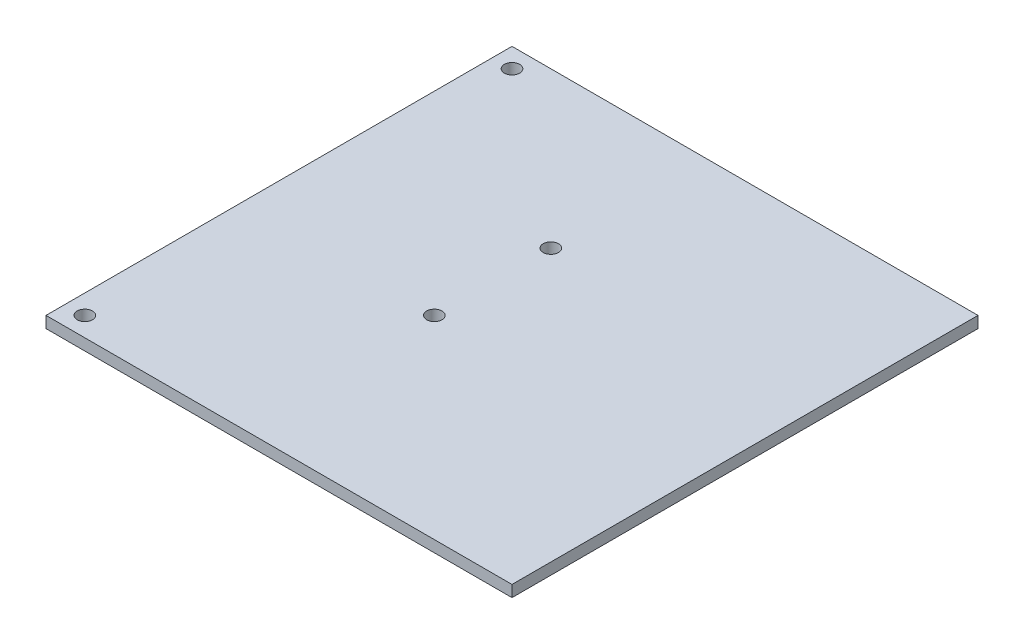
from build123d import *

# Parameters (mm, degrees)
SKETCH1_W           = 60.96
SKETCH1_H           = 60.96
SKETCH1_R           = 1
SKETCH1_R_2         = 0.5
BOSS_EXTRUDE1_DEPTH = 1.5
SKETCH1_3_R         = 0.5
CUT_EXTRUDE1_DEPTH  = 0.75


with BuildPart() as part:
    # Sketch1 → Boss-Extrude1 (new body)
    with BuildSketch(Plane(origin=(0, 0, 0), x_dir=(1, 0, 0), z_dir=(0, 1, 0))):
        with Locations((30.48, 30.48)):
            Rectangle(SKETCH1_W, SKETCH1_H)
        with Locations(Location((25.4, 40.64, 0), (0, 0, 270))):  # turned: the seam where the file's is
            Circle(SKETCH1_R, mode=Mode.SUBTRACT)
        with Locations(Location((25.4, 25.4, 0), (0, 0, 270))):  # turned: the seam where the file's is
            Circle(SKETCH1_R, mode=Mode.SUBTRACT)
        with Locations((10.16, 58.42)):
            Circle(SKETCH1_R_2, mode=Mode.SUBTRACT)
        with Locations(Location((2.54, 2.54, 0), (0, 0, 270))):  # turned: the seam where the file's is
            Circle(SKETCH1_R, mode=Mode.SUBTRACT)
        with Locations((10.16, 2.54)):
            Circle(SKETCH1_R_2, mode=Mode.SUBTRACT)
        with Locations((58.42, 15.24)):
            Circle(SKETCH1_R_2, mode=Mode.SUBTRACT)
        with Locations((58.42, 45.72)):
            Circle(SKETCH1_R_2, mode=Mode.SUBTRACT)
        with Locations(Location((2.54, 58.42, 0), (0, 0, 270))):  # turned: the seam where the file's is
            Circle(SKETCH1_R, mode=Mode.SUBTRACT)
        with Locations((10.16, 58.42)):
            Circle(SKETCH1_R_2)
        with Locations((58.42, 45.72)):
            Circle(SKETCH1_R_2)
        with Locations((58.42, 15.24)):
            Circle(SKETCH1_R_2)
        with Locations((10.16, 2.54)):
            Circle(SKETCH1_R_2)
    extrude(amount=BOSS_EXTRUDE1_DEPTH)

    # Sketch1_3 → Cut-Extrude1 (cut)
    with BuildSketch(Plane(origin=(0, 0, 0), x_dir=(1, 0, 0), z_dir=(0, 1, 0))):
        with Locations(Location((10.16, 2.54, 0), (0, 0, 270))):  # turned: the seam where the file's is
            Circle(SKETCH1_3_R)
        with Locations(Location((58.42, 15.24, 0), (0, 0, 270))):  # turned: the seam where the file's is
            Circle(SKETCH1_3_R)
        with Locations(Location((58.42, 45.72, 0), (0, 0, 90))):  # turned: the seam where the file's is
            Circle(SKETCH1_3_R)
        with Locations(Location((10.16, 58.42, 0), (0, 0, 90))):  # turned: the seam where the file's is
            Circle(SKETCH1_3_R)
    extrude(amount=CUT_EXTRUDE1_DEPTH, mode=Mode.SUBTRACT)


solid = part.part
